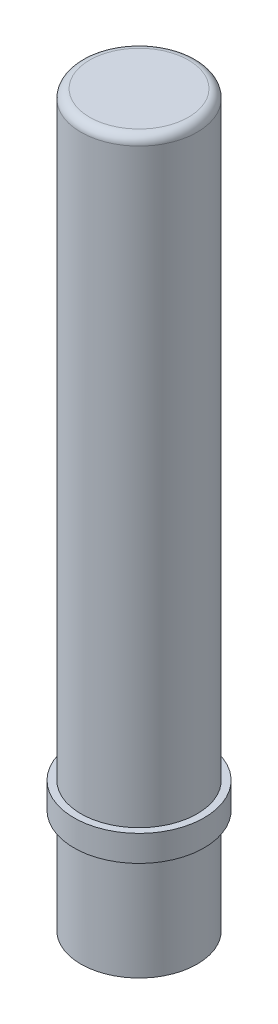
from build123d import *

# Parameters (mm, degrees)
SKETCH1_R           = 3.35
BOSS_EXTRUDE1_DEPTH = 42
SKETCH4_R           = 3.75
BOSS_EXTRUDE3_DEPTH = 1.5
FILLET1_R           = 0.5


with BuildPart() as part:
    # Sketch1 → Boss-Extrude1 (new body)
    with BuildSketch(Plane(origin=(0, 0, 0), x_dir=(1, 0, 0), z_dir=(0, 1, 0))):
        with Locations(Location((0, 0, 0), (0, 0, 270))):  # turned: the seam where the file's is
            Circle(SKETCH1_R)
    extrude(amount=BOSS_EXTRUDE1_DEPTH)

    # Sketch4 → Boss-Extrude3 (add)
    with BuildSketch(Plane(origin=(0, 6, 0), x_dir=(-1, 0, 0), z_dir=(0, -1, 0))):
        with Locations(Location((0, 0, 0), (0, 0, 90))):  # turned: the seam where the file's is
            Circle(SKETCH4_R)
    extrude(amount=-BOSS_EXTRUDE3_DEPTH)

    # Fillet1
    fillet1_edges = [part.edges().sort_by_distance(p)[0] for p in [
        (0, 42, -3.35),
    ]]
    fillet(fillet1_edges, radius=FILLET1_R)


solid = part.part
